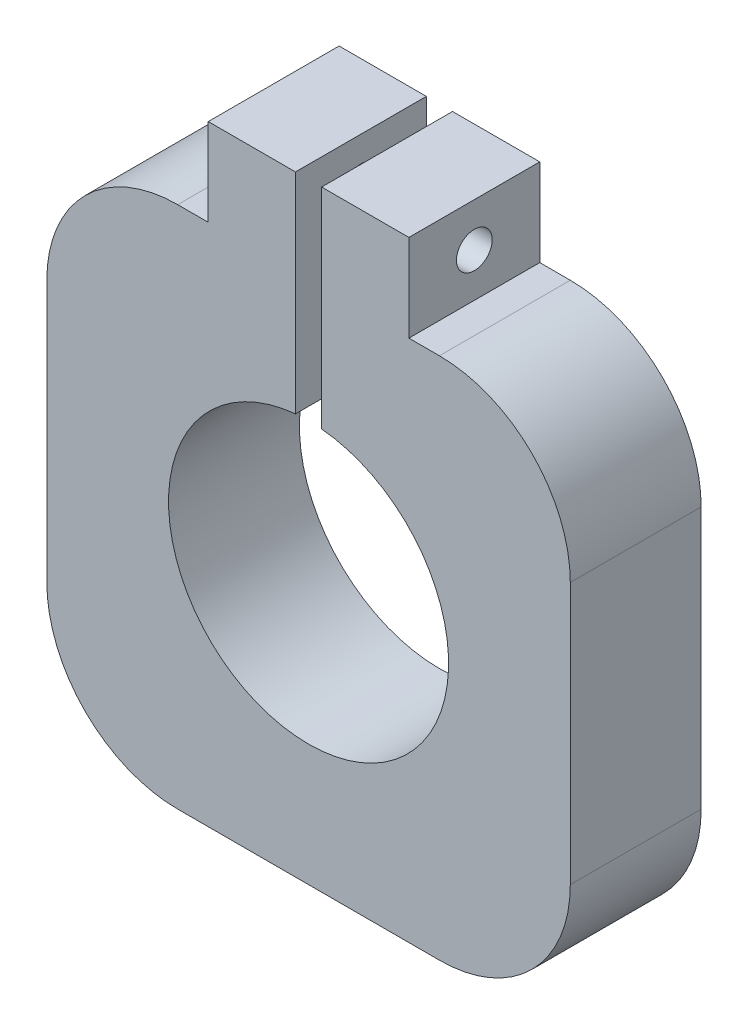
from build123d import *

# Parameters (mm, degrees)
BOSS_EXTRUDE2_DEPTH = 15
FILLET5_R           = 15
FILLET6_R           = 15
FILLET7_R           = 15
FILLET8_R           = 15
SKETCH4_R           = 2.05
CUT_EXTRUDE2_DEPTH  = 23


with BuildPart() as part:
    # Sketch3 → Boss-Extrude2 (new body)
    with BuildSketch(Plane.XY):
        with BuildLine():
            Line((-1.5, 40), (-1.5, 15.979752814))
            ThreePointArc((-1.5, 15.979752814), (0, -16.05), (1.5, 15.979752814))
            Line((1.5, 15.979752814), (1.5, 30))
            Line((1.5, 30), (1.5, 40))
            Line((1.5, 40), (11.5, 40))
            Line((11.5, 40), (11.5, 30))
            Line((11.5, 30), (30, 30))
            Line((30, 30), (30, -30))
            Line((30, -30), (-30, -30))
            Line((-30, -30), (-30, 30))
            Line((-30, 30), (-11.5, 30))
            Line((-11.5, 30), (-11.5, 40))
            Line((-11.5, 40), (-1.5, 40))
        make_face()
    extrude(amount=BOSS_EXTRUDE2_DEPTH)

    # Fillet5
    fillet5_edges = [part.edges().sort_by_distance(p)[0] for p in [
        (30, 30, 7.5),
    ]]
    fillet(fillet5_edges, radius=FILLET5_R)

    # Fillet6
    fillet6_edges = [part.edges().sort_by_distance(p)[0] for p in [
        (-30, 30, 7.5),
    ]]
    fillet(fillet6_edges, radius=FILLET6_R)

    # Fillet7
    fillet7_edges = [part.edges().sort_by_distance(p)[0] for p in [
        (-30, -30, 7.5),
    ]]
    fillet(fillet7_edges, radius=FILLET7_R)

    # Fillet8
    fillet8_edges = [part.edges().sort_by_distance(p)[0] for p in [
        (30, -30, 7.5),
    ]]
    fillet(fillet8_edges, radius=FILLET8_R)

    # Sketch4 → Cut-Extrude2 (cut)
    with BuildSketch(Plane(origin=(11.5, 0, 0), x_dir=(0, 0, -1), z_dir=(1, 0, 0))):
        with Locations((-7.5, 35)):
            Circle(SKETCH4_R)
    extrude(amount=-CUT_EXTRUDE2_DEPTH, mode=Mode.SUBTRACT)


solid = part.part
